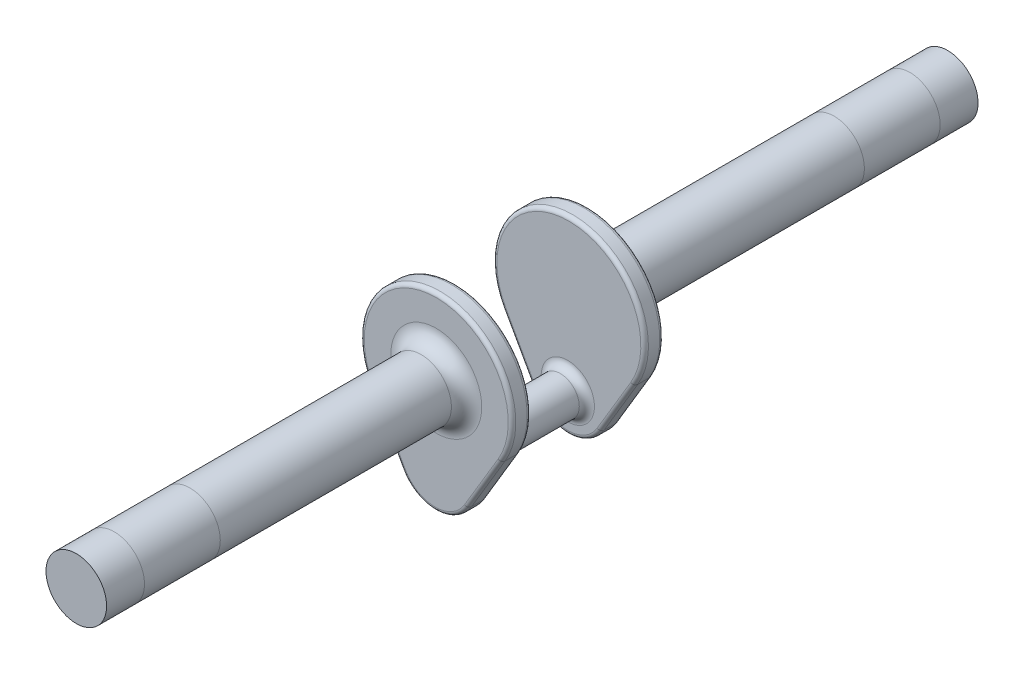
from build123d import *

# Parameters (mm, degrees)
EXTRUDE1_DEPTH = 6.35
SKETCH2_R      = 10.160444755
EXTRUDE2_DEPTH = 120.65
SKETCH3_R      = 6.389172444
EXTRUDE4_DEPTH = 19.05
FILLET1_R      = 2.54
FILLET2_R      = 5.08
FILLET3_R      = 1.27


with BuildPart() as part:
    # Sketch1 → Extrude1 (new body)
    with BuildSketch(Plane.XY):
        with BuildLine():
            Line((-22.174672946, -12.387246657), (-11.445580084, -31.593623329))
            ThreePointArc((-11.445580084, -31.593623329), (-0.537347603, -38.098737014), (10.550006681, -31.903850826))
            Line((10.550006681, -31.903850826), (21.816500584, -13.007701651))
            ThreePointArc((21.816500584, -13.007701651), (0.358207984, 25.397474029), (-22.174672946, -12.387246657))
        make_face()
    extrude(amount=EXTRUDE1_DEPTH)

    # Sketch2 → Extrude2 (add)
    with BuildSketch(Plane(origin=(0, 0, 0), x_dir=(-1, 0, 0), z_dir=(0, 0, -1))):
        Circle(SKETCH2_R)
    extrude(amount=EXTRUDE2_DEPTH)

    # Sketch3 → Extrude4 (add)
    with BuildSketch(Plane.XY.offset(6.35)):
        with Locations((-0.358243611, -25.4)):
            Circle(SKETCH3_R)
    extrude(amount=EXTRUDE4_DEPTH)

    # Fillet1
    fillet1_edges = [part.edges().sort_by_distance(p)[0] for p in [
        (-6.747416055, -25.4, 6.35),
    ]]
    fillet(fillet1_edges, radius=FILLET1_R)

    # Fillet2
    fillet2_edges = [part.edges().sort_by_distance(p)[0] for p in [
        (10.160444755, 0, 0),
    ]]
    fillet(fillet2_edges, radius=FILLET2_R)

    # Fillet3
    fillet3_edges = [part.edges().sort_by_distance(p)[0] for p in [
        (16.183253633, -22.455776239, 6.35),
        (-0.537347603, -38.098737014, 6.35),
        (-16.810126515, -21.990434993, 6.35),
        (16.183253633, -22.455776239, 0),
        (-0.537347603, -38.098737014, 0),
        (-16.810126515, -21.990434993, 0),
        (0.358207984, 25.397474029, 6.35),
        (0.358207984, 25.397474029, 0),
    ]]
    fillet(fillet3_edges, radius=FILLET3_R)

    # Mirror2: part across plane


with BuildPart() as part_1:
    add(part.part)
    add(part.part.mirror(Plane(origin=(-0.358243611, -25.4, 25.4), x_dir=(1, 0, 0), z_dir=(0, 0, 1))))


solid = part_1.part
